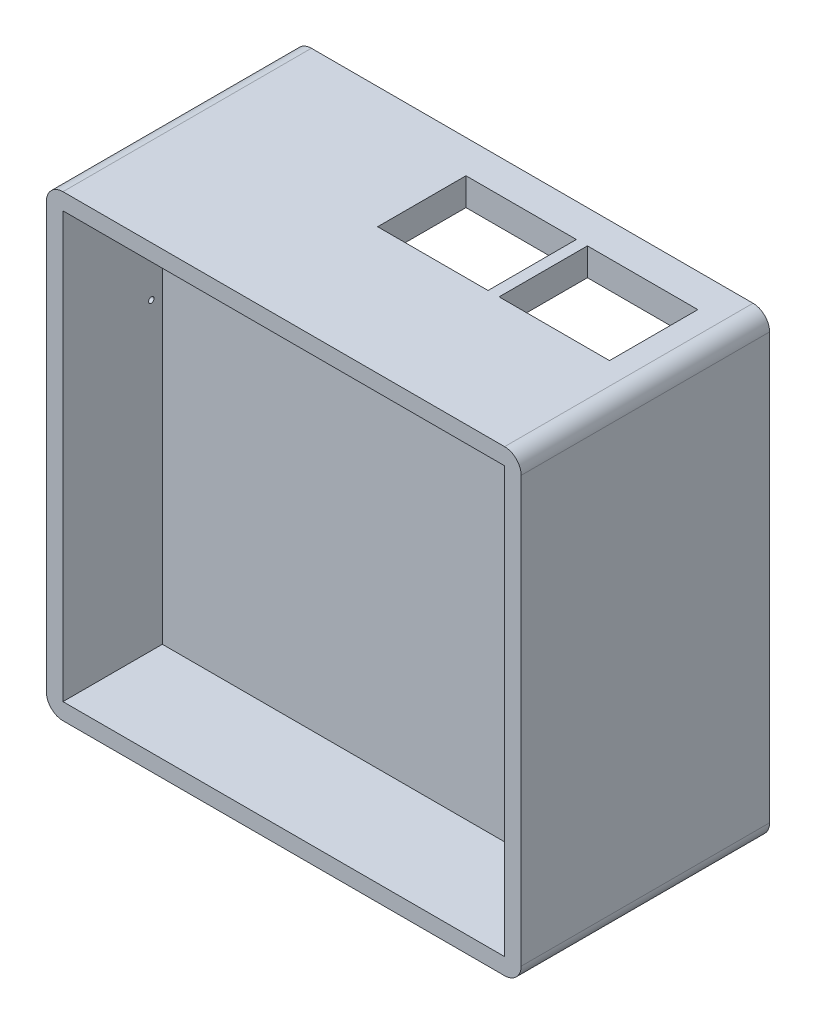
from build123d import *

# Parameters (mm, degrees)
ESQUISSE1_W             = 86
ESQUISSE1_H             = 83
BOSS_EXTRU_1_DEPTH      = 45
ESQUISSE2_W             = 82
ESQUISSE2_H             = 79
ENL_V_MAT_EXTRU_1_DEPTH = 3
ESQUISSE3_W             = 76
ESQUISSE3_H             = 73
ENL_V_MAT_EXTRU_2_DEPTH = 20
ESQUISSE5_W             = 80
ESQUISSE5_H             = 77
ENL_V_MAT_EXTRU_3_DEPTH = 18
ESQUISSE7_W             = 20
ESQUISSE7_H             = 16
ENL_V_MAT_EXTRU_4_DEPTH = 18
ESQUISSE8_W             = 20
ESQUISSE8_H             = 16
ENL_V_MAT_EXTRU_5_DEPTH = 18
ESQUISSE10_W            = 10
ESQUISSE10_H            = 25
ENL_V_MAT_EXTRU_6_DEPTH = 18
ESQUISSE12_R            = 0.5
ENL_V_MAT_EXTRU_9_DEPTH = 18
CONG_2_R                = 3


with BuildPart() as part:
    # Esquisse1 → Boss.-Extru.1 (new body)
    with BuildSketch(Plane.XY):
        with Locations((2.925773196, -12.508247423)):
            Rectangle(ESQUISSE1_W, ESQUISSE1_H)
    extrude(amount=BOSS_EXTRU_1_DEPTH)

    # Esquisse2 → Enlèv. mat.-Extru.1 (cut)
    with BuildSketch(Plane(origin=(0, 0, 0), x_dir=(-1, 0, 0), z_dir=(0, 0, -1))):
        with Locations((-2.925773196, -12.508247423)):
            Rectangle(ESQUISSE2_W, ESQUISSE2_H)
    extrude(amount=-ENL_V_MAT_EXTRU_1_DEPTH, mode=Mode.SUBTRACT)

    # Esquisse3 → Enlèv. mat.-Extru.2 (cut)
    with BuildSketch(Plane(origin=(0, 0, 3), x_dir=(-1, 0, 0), z_dir=(0, 0, -1))):
        with Locations((-2.925773196, -12.508247423)):
            Rectangle(ESQUISSE3_W, ESQUISSE3_H)
    extrude(amount=-ENL_V_MAT_EXTRU_2_DEPTH, mode=Mode.SUBTRACT)

    # Esquisse5 → Enlèv. mat.-Extru.3 (cut)
    with BuildSketch(Plane.XY.offset(45)):
        with Locations((2.925773196, -12.508247423)):
            Rectangle(ESQUISSE5_W, ESQUISSE5_H)
    extrude(amount=-ENL_V_MAT_EXTRU_3_DEPTH, mode=Mode.SUBTRACT)

    # Esquisse7 → Enlèv. mat.-Extru.4 (cut)
    with BuildSketch(Plane(origin=(0, 28.991752577, 0), x_dir=(1, 0, 0), z_dir=(0, 1, 0))):
        with Locations((28.925773196, -14)):
            Rectangle(ESQUISSE7_W, ESQUISSE7_H)
    extrude(amount=-ENL_V_MAT_EXTRU_4_DEPTH, mode=Mode.SUBTRACT)

    # Esquisse8 → Enlèv. mat.-Extru.5 (cut)
    with BuildSketch(Plane(origin=(0, 28.991752577, 0), x_dir=(1, 0, 0), z_dir=(0, 1, 0))):
        with Locations((6.925773196, -14)):
            Rectangle(ESQUISSE8_W, ESQUISSE8_H)
    extrude(amount=-ENL_V_MAT_EXTRU_5_DEPTH, mode=Mode.SUBTRACT)

    # Esquisse10 → Enlèv. mat.-Extru.6 (cut)
    with BuildSketch(Plane.ZY.offset(40.074226804)):
        with Locations((17, 11.491752577)):
            Rectangle(ESQUISSE10_W, ESQUISSE10_H)
    extrude(amount=-ENL_V_MAT_EXTRU_6_DEPTH, mode=Mode.SUBTRACT)

    # Esquisse12 → Enlèv. mat.-Extru.9 (cut)
    with BuildSketch(Plane.ZY.offset(40.074226804)):
        with Locations((29, 3.991752577)):
            Circle(ESQUISSE12_R)
    extrude(amount=-ENL_V_MAT_EXTRU_9_DEPTH, mode=Mode.SUBTRACT)

    # Congé2
    cong_2_edges = [part.edges().sort_by_distance(p)[0] for p in [
        (-40.074226804, 28.991752577, 22.5),
        (45.925773196, 28.991752577, 22.5),
        (45.925773196, -54.008247423, 22.5),
        (-40.074226804, -54.008247423, 22.5),
    ]]
    fillet(cong_2_edges, radius=CONG_2_R)


solid = part.part
